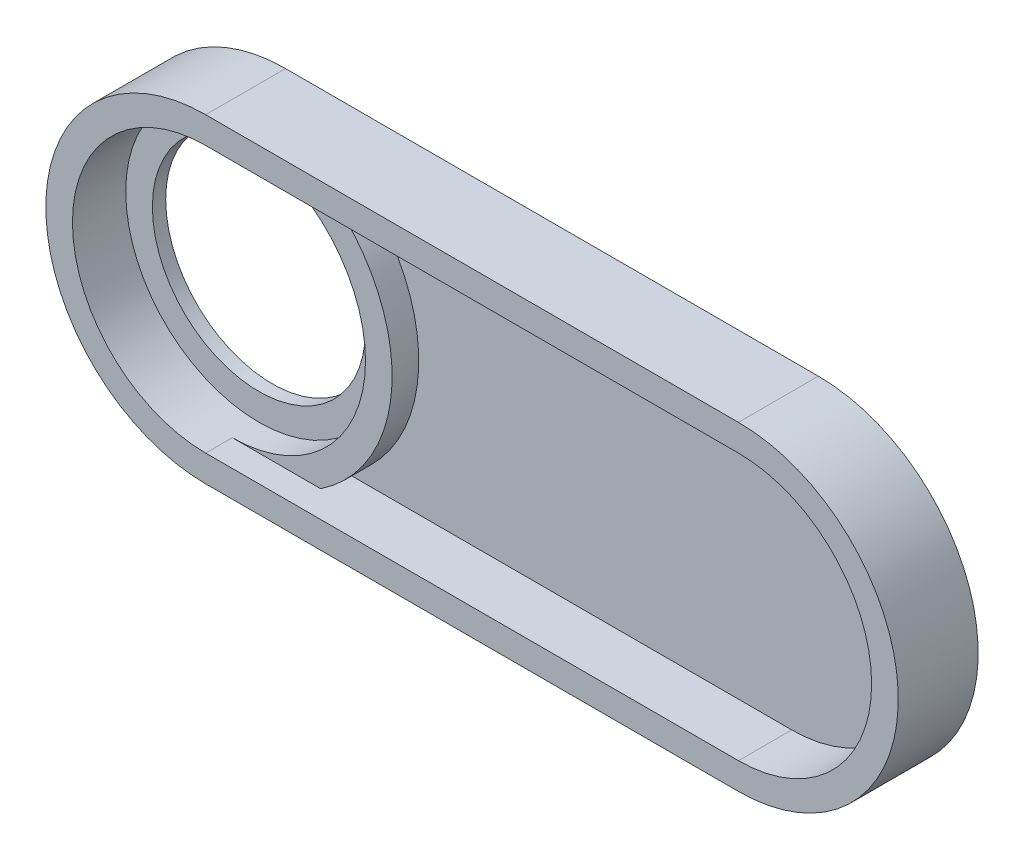
from build123d import *

# Parameters (mm, degrees)
SKETCH1_R           = 40
BOSS_EXTRUDE1_DEPTH = 10
SKETCH2_R           = 52.5
CUT_EXTRUDE1_DEPTH  = 5
SKETCH3_R           = 50
BOSS_EXTRUDE2_DEPTH = 10
BOSS_EXTRUDE3_DEPTH = 20


with BuildPart() as part:
    # Sketch1 → Boss-Extrude1 (new body)
    with BuildSketch(Plane.XY):
        with BuildLine():
            Line((0, 60), (200, 60))
            ThreePointArc((200, 60), (260, 0), (200, -60))
            Line((200, -60), (0, -60))
            ThreePointArc((0, -60), (-60, 0), (0, 60))
        make_face()
        Circle(SKETCH1_R, mode=Mode.SUBTRACT)
    extrude(amount=BOSS_EXTRUDE1_DEPTH)

    # Sketch2 → Cut-Extrude1 (cut)
    with BuildSketch(Plane(origin=(0, 0, 0), x_dir=(-1, 0, 0), z_dir=(0, 0, -1))):
        Circle(SKETCH2_R)
    extrude(amount=-CUT_EXTRUDE1_DEPTH, mode=Mode.SUBTRACT)

    # Sketch3 → Boss-Extrude2 (add)
    with BuildSketch(Plane.XY.offset(10)):
        with BuildLine():
            ThreePointArc((0, -60), (42.426406871, -42.426406871), (60, 0))
            ThreePointArc((60, 0), (42.426406871, 42.426406871), (0, 60))
            ThreePointArc((0, 60), (-60, 0), (0, -60))
        make_face()
        Circle(SKETCH3_R, mode=Mode.SUBTRACT)
    extrude(amount=BOSS_EXTRUDE2_DEPTH)

    # Sketch4 → Boss-Extrude3 (add)
    with BuildSketch(Plane.XY.offset(10)):
        with BuildLine():
            Line((0, -60), (200, -60))
            ThreePointArc((200, -60), (260, 0), (200, 60))
            Line((200, 60), (0, 60))
            ThreePointArc((0, 60), (-60, 0), (0, -60))
        make_face()
        with BuildLine():
            Line((0, -50), (200, -50))
            ThreePointArc((200, -50), (250, 0), (200, 50))
            Line((200, 50), (0, 50))
            ThreePointArc((0, 50), (-50, 0), (0, -50))
        make_face(mode=Mode.SUBTRACT)
    extrude(amount=BOSS_EXTRUDE3_DEPTH)


solid = part.part
